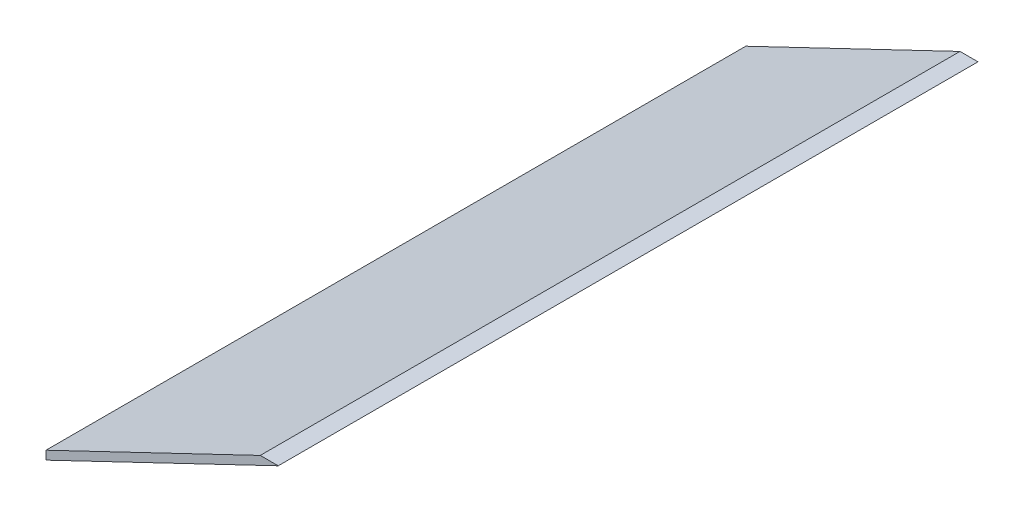
from build123d import *

# Parameters (mm, degrees)
AUFSATZ_LINEAR_AUSTRAGEN1_DEPTH = 450


with BuildPart() as part:
    # Skizze1 → Aufsatz-Linear austragen1 (new body)
    with BuildSketch(Plane.XY):
        Polygon((97.5, 188.043734255), (97.5, 182.5), (246.858259494, 254.02367356), (235.281637962, 254.02367356), align=None)
    extrude(amount=AUFSATZ_LINEAR_AUSTRAGEN1_DEPTH)


solid = part.part
